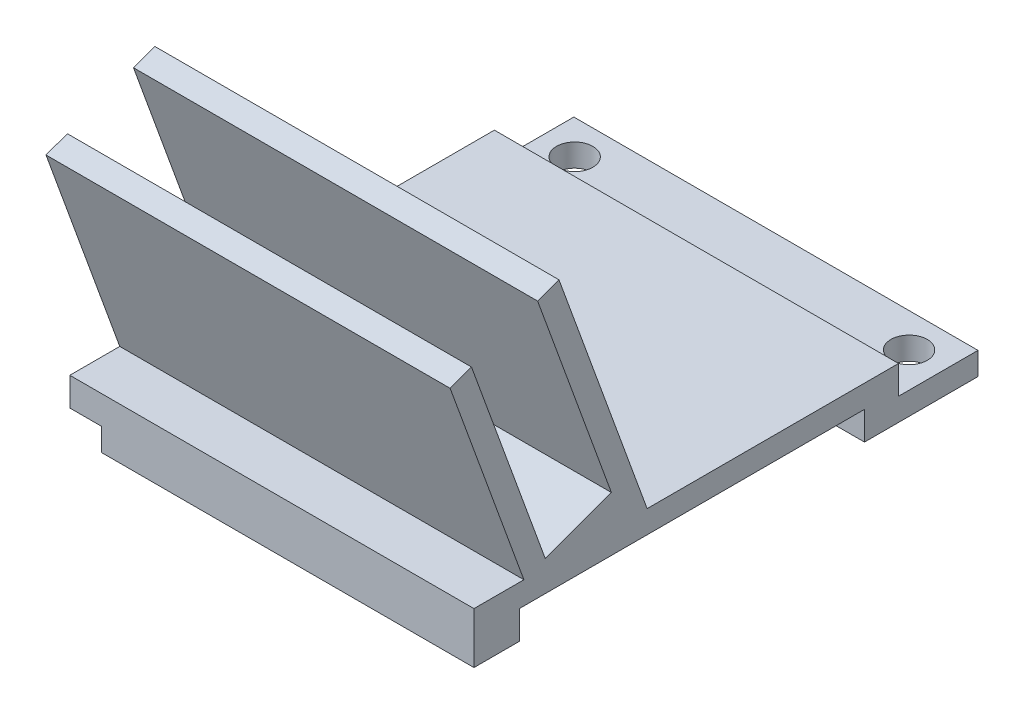
from build123d import *

# Parameters (mm, degrees)
SKETCH1_R           = 1.4
BOSS_EXTRUDE1_DEPTH = 2
SKETCH2_W           = 35.6
SKETCH2_H           = 4
BOSS_EXTRUDE2_DEPTH = 2.5
SKETCH3_W           = 35.6
SKETCH3_H           = 2
BOSS_EXTRUDE3_DEPTH = 30
SKETCH4_W           = 3
SKETCH4_H           = 10
BOSS_EXTRUDE4_DEPTH = 2.5
SKETCH5_W           = 35.6
SKETCH5_H           = 2
BOSS_EXTRUDE5_DEPTH = 20
SKETCH6_W           = 29.6
SKETCH6_H           = 4
BOSS_EXTRUDE6_DEPTH = 2.5
SKETCH7_W           = 35.6
SKETCH7_H           = 24.5
BOSS_EXTRUDE7_DEPTH = 4.4
SKETCH8_W           = 29.6
SKETCH8_H           = 2.5
CUT_EXTRUDE1_DEPTH  = 4.4
SKETCH9_W           = 3
SKETCH9_H           = 2.5
CUT_EXTRUDE2_DEPTH  = 4.4
SKETCH10_W          = 35.6
SKETCH10_H          = 20
CUT_EXTRUDE3_DEPTH  = 4.4
SKETCH11_R          = 1.6
CUT_EXTRUDE4_DEPTH  = 10
SKETCH12_W          = 35.6
SKETCH12_H          = 2.5
CUT_EXTRUDE5_DEPTH  = 1
SKETCH13_W          = 35.6
SKETCH13_H          = 10.25
CUT_EXTRUDE6_DEPTH  = 1
SKETCH14_W          = 35.6
SKETCH14_H          = 19
BOSS_EXTRUDE8_DEPTH = 0.05
BOSS_EXTRUDE9_DEPTH = 35.6
SKETCH16_W          = 35.6
SKETCH16_H          = 16.293178749
CUT_EXTRUDE7_DEPTH  = 29
CUT_EXTRUDE8_DEPTH  = 6.2
SKETCH19_W          = 6
SKETCH19_H          = 2.5
CUT_EXTRUDE9_DEPTH  = 29
SKETCH20_W          = 2.8
SKETCH20_H          = 2.8
CUT_EXTRUDE10_DEPTH = 2


with BuildPart() as part:
    # Sketch1 → Boss-Extrude1 (new body)
    with BuildSketch(Plane(origin=(0, 0, 0), x_dir=(1, 0, 0), z_dir=(0, 1, 0))):
        Polygon((-17.8, 3), (17.8, 3), (17.8, -3), (17.8, -7), (-17.8, -7), (-17.8, -3), align=None)
        with Locations(Location((-14.73, 0, 0), (0, 0, 270))):
            Circle(SKETCH1_R, mode=Mode.SUBTRACT)
        with Locations(Location((14.73, 0, 0), (0, 0, 270))):
            Circle(SKETCH1_R, mode=Mode.SUBTRACT)
    extrude(amount=BOSS_EXTRUDE1_DEPTH)

    # Sketch2 → Boss-Extrude2 (add)
    with BuildSketch(Plane(origin=(0, 2, 0), x_dir=(1, 0, 0), z_dir=(0, 1, 0))):
        with Locations((0, -5)):
            Rectangle(SKETCH2_W, SKETCH2_H)
    extrude(amount=BOSS_EXTRUDE2_DEPTH)

    # Sketch3 → Boss-Extrude3 (add)
    with BuildSketch(Plane.XY.offset(7)):
        with Locations((0, 3.5)):
            Rectangle(SKETCH3_W, SKETCH3_H)
    extrude(amount=BOSS_EXTRUDE3_DEPTH)

    # Sketch4 → Boss-Extrude4 (add)
    with BuildSketch(Plane.XZ.offset(-2.5)):
        with Locations((-16.3, 32)):
            Rectangle(SKETCH4_W, SKETCH4_H)
        with Locations((16.3, 32)):
            Rectangle(SKETCH4_W, SKETCH4_H)
    extrude(amount=BOSS_EXTRUDE4_DEPTH)

    # Sketch5 → Boss-Extrude5 (add)
    with BuildSketch(Plane(origin=(0, 4.5, 0), x_dir=(1, 0, 0), z_dir=(0, 1, 0))):
        with Locations((0, -36)):
            Rectangle(SKETCH5_W, SKETCH5_H)
        with Locations((0, -27.75)):
            Rectangle(SKETCH5_W, SKETCH5_H)
    extrude(amount=BOSS_EXTRUDE5_DEPTH)

    # Sketch6 → Boss-Extrude6 (add)
    with BuildSketch(Plane.XZ.offset(-2.5)):
        with Locations((0, 35)):
            Rectangle(SKETCH6_W, SKETCH6_H)
    extrude(amount=BOSS_EXTRUDE6_DEPTH)

    # Sketch7 → Boss-Extrude7 (add)
    with BuildSketch(Plane.XY.offset(37)):
        with Locations((0, 12.25)):
            Rectangle(SKETCH7_W, SKETCH7_H)
    extrude(amount=BOSS_EXTRUDE7_DEPTH)

    # Sketch8 → Cut-Extrude1 (cut)
    with BuildSketch(Plane(origin=(0, 0, 33), x_dir=(-1, 0, 0), z_dir=(0, 0, -1))):
        with Locations((0, 1.25)):
            Rectangle(SKETCH8_W, SKETCH8_H)
    extrude(amount=-CUT_EXTRUDE1_DEPTH, mode=Mode.SUBTRACT)

    # Sketch9 → Cut-Extrude2 (cut)
    with BuildSketch(Plane(origin=(0, 0, 27), x_dir=(-1, 0, 0), z_dir=(0, 0, -1))):
        with Locations((-16.3, 1.25)):
            Rectangle(SKETCH9_W, SKETCH9_H)
        with Locations((16.3, 1.25)):
            Rectangle(SKETCH9_W, SKETCH9_H)
    extrude(amount=-CUT_EXTRUDE2_DEPTH, mode=Mode.SUBTRACT)

    # Sketch10 → Cut-Extrude3 (cut)
    with BuildSketch(Plane.XY.offset(41.4)):
        with Locations((0, 14.5)):
            Rectangle(SKETCH10_W, SKETCH10_H)
    extrude(amount=-CUT_EXTRUDE3_DEPTH, mode=Mode.SUBTRACT)

    # Sketch11 → Cut-Extrude4 (cut)
    with BuildSketch(Plane.XZ):
        with Locations(Location((-14.73, 0, 0), (0, 0, 270))):
            Circle(SKETCH11_R)
        with Locations(Location((14.73, 0, 0), (0, 0, 270))):
            Circle(SKETCH11_R)
    extrude(amount=-CUT_EXTRUDE4_DEPTH, mode=Mode.SUBTRACT)

    # Sketch12 → Cut-Extrude5 (cut)
    with BuildSketch(Plane(origin=(0, 0, 3), x_dir=(-1, 0, 0), z_dir=(0, 0, -1))):
        with Locations((0, 3.25)):
            Rectangle(SKETCH12_W, SKETCH12_H)
    extrude(amount=-CUT_EXTRUDE5_DEPTH, mode=Mode.SUBTRACT)

    # Sketch13 → Cut-Extrude6 (cut)
    with BuildSketch(Plane(origin=(0, 24.5, 0), x_dir=(1, 0, 0), z_dir=(0, 1, 0))):
        with Locations((0, -31.875)):
            Rectangle(SKETCH13_W, SKETCH13_H)
    extrude(amount=-CUT_EXTRUDE6_DEPTH, mode=Mode.SUBTRACT)

    # Sketch14 → Boss-Extrude8 (add)
    with BuildSketch(Plane.XY.offset(28.75)):
        with Locations((0, 14)):
            Rectangle(SKETCH14_W, SKETCH14_H)
    extrude(amount=BOSS_EXTRUDE8_DEPTH)

    # Sketch15 → Boss-Extrude9 (add)
    with BuildSketch(Plane.ZY.offset(17.8)):
        Polygon((35.120614758, 5.184040287), (41.618997482, 23.038200082), (43.498382723, 22.354159795), (37, 4.5), (34.871644455, 4.5), (26.145386721, 4.5), (27.415135268, 7.988605462), (33.913517991, 25.842765257), (35.792903233, 25.15872497), (29.29452051, 7.304565175), align=None)
    extrude(amount=-BOSS_EXTRUDE9_DEPTH)

    # Sketch16 → Cut-Extrude7 (cut)
    with BuildSketch(Plane(origin=(0, -7.876565314, 21.640685344), x_dir=(-1, 0, 0), z_dir=(0, 0.34202014332566366, -0.9396926207859103))):
        with Locations((0, 23.085226048)):
            Rectangle(SKETCH16_W, SKETCH16_H)
    extrude(amount=CUT_EXTRUDE7_DEPTH, mode=Mode.SUBTRACT)


with BuildPart() as body_2:
    # of the pieces the cut leaves, the one that is kept (cut_extrude7_keep)
    add(part.part.solids().sort_by_distance((-17.8, 0, -3))[0])

    # Sketch17 → Cut-Extrude8 (cut)
    with BuildSketch(Plane(origin=(0, -8.560605601, 23.520070585), x_dir=(1, 0, 0), z_dir=(0, -0.34202014332566366, 0.9396926207859103))):
        Polygon((-17.8, 33.565068136), (-17.8, 35.883362097), (17.8, 35.883362097), (17.8, 33.565068136), (17.8, 16.883362097), (-17.8, 16.883362097), align=None)
    extrude(amount=CUT_EXTRUDE8_DEPTH, mode=Mode.SUBTRACT)

    # Sketch19 → Cut-Extrude9 (cut)
    with BuildSketch(Plane.ZY.offset(-14.8)):
        with Locations((34.4, 1.25)):
            Rectangle(SKETCH19_W, SKETCH19_H)
    extrude(amount=-CUT_EXTRUDE9_DEPTH, mode=Mode.SUBTRACT)

    # Sketch20 → Cut-Extrude10 (cut)
    with BuildSketch(Plane.XZ):
        with Locations((-16.4, 40)):
            Rectangle(SKETCH20_W, SKETCH20_H)
    extrude(amount=-CUT_EXTRUDE10_DEPTH, mode=Mode.SUBTRACT)


solid = body_2.part
